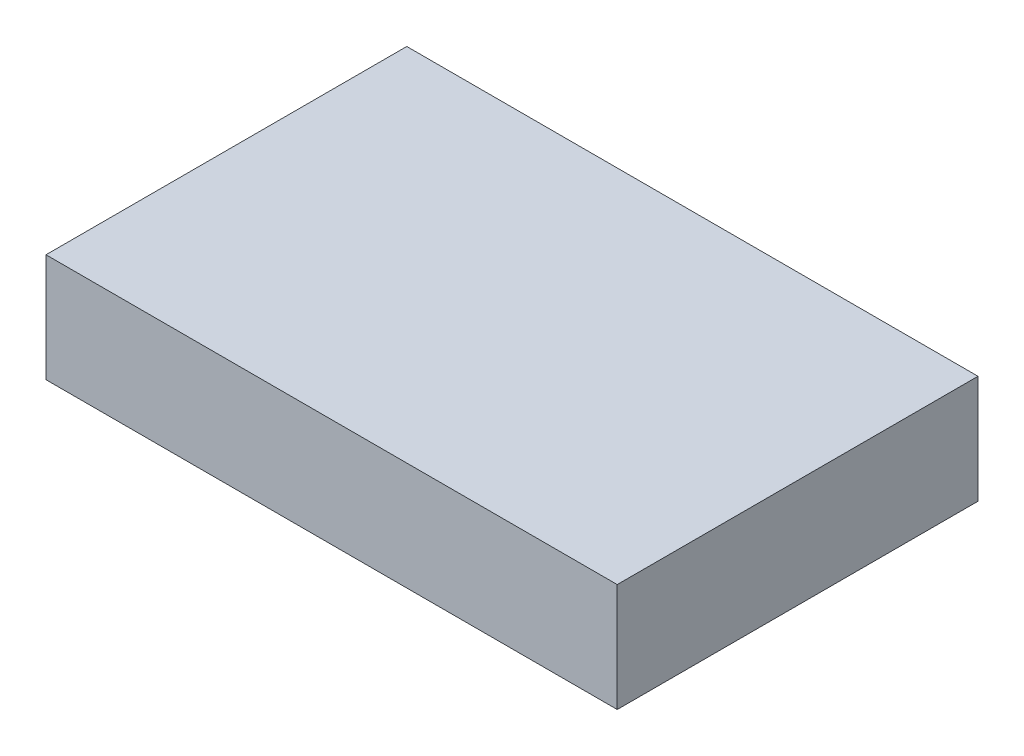
from build123d import *

# Parameters (mm, degrees)
ESQUISSE1_W        = 95
ESQUISSE1_H        = 60
BOSS_EXTRU_1_DEPTH = 18


with BuildPart() as part:
    # Esquisse1 → Boss.-Extru.1 (new body)
    with BuildSketch(Plane(origin=(0, 0, 0), x_dir=(1, 0, 0), z_dir=(0, 1, 0))):
        with Locations((-4.691291333, 5.016095971)):
            Rectangle(ESQUISSE1_W, ESQUISSE1_H)
    extrude(amount=BOSS_EXTRU_1_DEPTH)


solid = part.part
